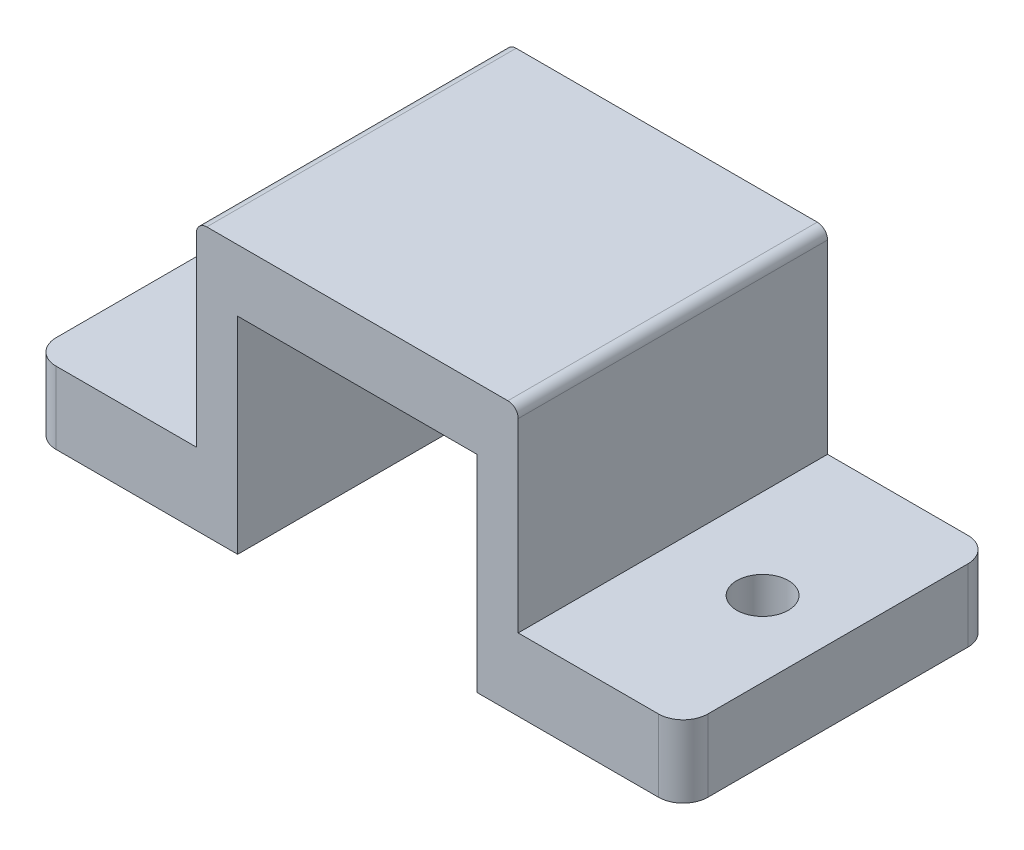
from build123d import *

# Parameters (mm, degrees)
BOSS_EXTRUDE1_DEPTH = 7.5
SKETCH3_R           = 1.25
BOSS_EXTRUDE2_DEPTH = 3.5


with BuildPart() as part:
    # Sketch1 → Boss-Extrude1 (new body, symmetric)
    with BuildSketch(Plane.XY):
        with BuildLine():
            Line((-5.8, 0), (-5.8, 10))
            Line((-5.8, 10), (5.8, 10))
            Line((5.8, 10), (5.8, 0))
            Line((5.8, 0), (7.8, 0))
            Line((7.8, 0), (7.8, 12.5))
            ThreePointArc((7.8, 12.5), (7.653553391, 12.853553391), (7.3, 13))
            Line((7.3, 13), (5.857116976, 13))
            Line((5.857116976, 13), (-7.3, 13))
            ThreePointArc((-7.3, 13), (-7.653553391, 12.853553391), (-7.8, 12.5))
            Line((-7.8, 12.5), (-7.8, 10))
            Line((-7.8, 10), (-7.8, 0))
            Line((-7.8, 0), (-5.8, 0))
        make_face()
    extrude(amount=BOSS_EXTRUDE1_DEPTH, both=True)

    # Sketch3 → Boss-Extrude2 (add)
    with BuildSketch(Plane(origin=(0, 0, 0), x_dir=(1, 0, 0), z_dir=(0, 1, 0))):
        with BuildLine():
            ThreePointArc((-14.6, -7.5), (-15.448528137, -7.148528137), (-15.8, -6.3))
            Line((-15.8, -6.3), (-15.8, 6.3))
            ThreePointArc((-15.8, 6.3), (-15.448528137, 7.148528137), (-14.6, 7.5))
            Line((-14.6, 7.5), (-7.8, 7.5))
            Line((-7.8, 7.5), (-7.8, -7.5))
            Line((-7.8, -7.5), (-14.6, -7.5))
        make_face()
        with Locations((-12.15, 0)):
            Circle(SKETCH3_R, mode=Mode.SUBTRACT)
        with BuildLine():
            ThreePointArc((14.6, 7.5), (15.448528137, 7.148528137), (15.8, 6.3))
            Line((15.8, 6.3), (15.8, -6.3))
            ThreePointArc((15.8, -6.3), (15.448528137, -7.148528137), (14.6, -7.5))
            Line((14.6, -7.5), (7.8, -7.5))
            Line((7.8, -7.5), (7.8, 7.5))
            Line((7.8, 7.5), (14.6, 7.5))
        make_face()
        with Locations((12.15, 0)):
            Circle(SKETCH3_R, mode=Mode.SUBTRACT)
    extrude(amount=BOSS_EXTRUDE2_DEPTH)


solid = part.part
